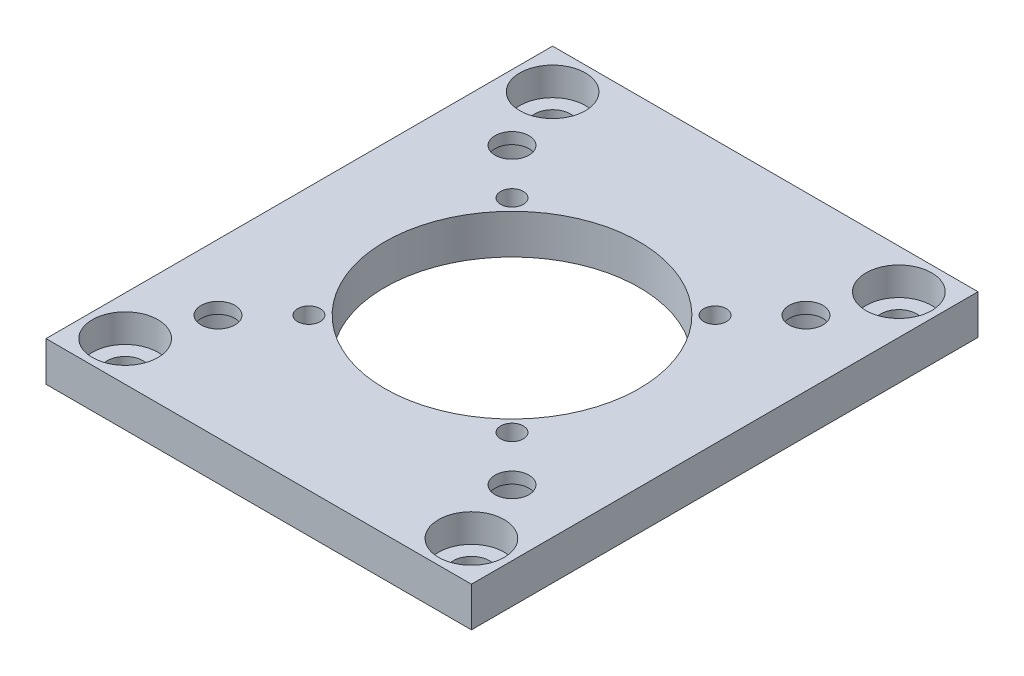
from build123d import *

# Parameters (mm, degrees)
SKETCH2_W           = 37.621859492
SKETCH2_H           = 44.8
SKETCH2_R           = 11.25
SKETCH2_R_2         = 1.5
SKETCH2_R_3         = 1
SKETCH2_R_4         = 1.6
BOSS_EXTRUDE1_DEPTH = 3.5
SKETCH4_R           = 2.9
CUT_EXTRUDE1_DEPTH  = 2.5
SKETCH6_R           = 2.9
CUT_EXTRUDE2_DEPTH  = 2.5


with BuildPart() as part:
    # Sketch2 → Boss-Extrude1 (new body)
    with BuildSketch(Plane(origin=(0, 0, 0), x_dir=(1, 0, 0), z_dir=(0, 1, 0))):
        Rectangle(SKETCH2_W, SKETCH2_H)
        Circle(SKETCH2_R, mode=Mode.SUBTRACT)
        with Locations((-13, 13)):
            Circle(SKETCH2_R_2, mode=Mode.SUBTRACT)
        with Locations((13, 13)):
            Circle(SKETCH2_R_2, mode=Mode.SUBTRACT)
        with Locations((13, -13)):
            Circle(SKETCH2_R_2, mode=Mode.SUBTRACT)
        with Locations((-13, -13)):
            Circle(SKETCH2_R_2, mode=Mode.SUBTRACT)
        with Locations((8.98, 8.98)):
            Circle(SKETCH2_R_3, mode=Mode.SUBTRACT)
        with Locations((-8.98, 8.98)):
            Circle(SKETCH2_R_3, mode=Mode.SUBTRACT)
        with Locations((8.98, -8.98)):
            Circle(SKETCH2_R_3, mode=Mode.SUBTRACT)
        with Locations((-8.98, -8.98)):
            Circle(SKETCH2_R_3, mode=Mode.SUBTRACT)
        with Locations((-15.31, 18.9)):
            Circle(SKETCH2_R_4, mode=Mode.SUBTRACT)
        with Locations((15.31, 18.9)):
            Circle(SKETCH2_R_4, mode=Mode.SUBTRACT)
        with Locations((15.31, -18.9)):
            Circle(SKETCH2_R_4, mode=Mode.SUBTRACT)
        with Locations((-15.31, -18.9)):
            Circle(SKETCH2_R_4, mode=Mode.SUBTRACT)
    extrude(amount=BOSS_EXTRUDE1_DEPTH)

    # Sketch4 → Cut-Extrude1 (cut)
    with BuildSketch(Plane.XZ):
        with Locations((-13, -13)):
            Circle(SKETCH4_R)
        with Locations((13, -13)):
            Circle(SKETCH4_R)
        with Locations((13, 13)):
            Circle(SKETCH4_R)
        with Locations((-13, 13)):
            Circle(SKETCH4_R)
    extrude(amount=-CUT_EXTRUDE1_DEPTH, mode=Mode.SUBTRACT)

    # Sketch6 → Cut-Extrude2 (cut)
    with BuildSketch(Plane(origin=(0, 3.5, 0), x_dir=(1, 0, 0), z_dir=(0, 1, 0))):
        with Locations((-15.31, 18.9)):
            Circle(SKETCH6_R)
        with Locations((15.31, -18.9)):
            Circle(SKETCH6_R)
        with Locations((15.309998981, 18.900002337)):
            Circle(SKETCH6_R)
        with Locations((-15.31, -18.9)):
            Circle(SKETCH6_R)
    extrude(amount=-CUT_EXTRUDE2_DEPTH, mode=Mode.SUBTRACT)


solid = part.part
